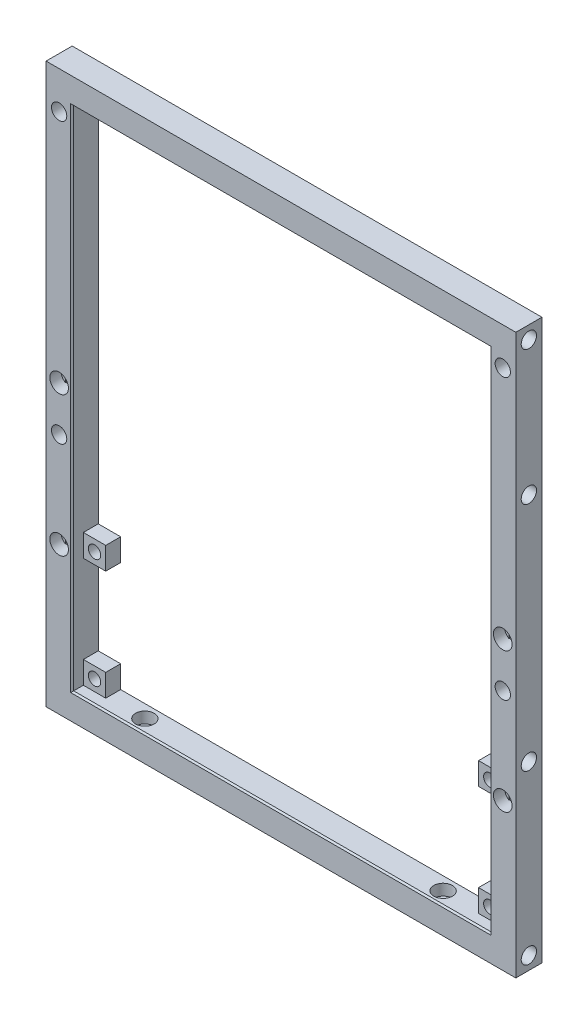
from build123d import *

# Parameters (mm, degrees)
SKETCH1_W           = 126
SKETCH1_H           = 150
SKETCH1_W_2         = 112
SKETCH1_H_2         = 136
BOSS_EXTRUDE1_DEPTH = 7
SKETCH2_R           = 2.05
CUT_EXTRUDE1_DEPTH  = 6
SKETCH3_R           = 1.35
CUT_EXTRUDE2_DEPTH  = 8
SKETCH4_R           = 2.5
CUT_EXTRUDE3_DEPTH  = 3
SKETCH5_R           = 1.35
CUT_EXTRUDE4_DEPTH  = 8
SKETCH6_R           = 2.5
CUT_EXTRUDE5_DEPTH  = 3
CUT_EXTRUDE6_DEPTH  = 0.2
SKETCH8_W           = 2.7
SKETCH8_H           = 2.7
CUT_EXTRUDE7_DEPTH  = 0.2
SKETCH9_R           = 2.05
CUT_EXTRUDE8_DEPTH  = 8
SKETCH10_W          = 6
SKETCH10_H          = 6
BOSS_EXTRUDE2_DEPTH = 4
SKETCH11_R          = 1.65
CUT_EXTRUDE9_DEPTH  = 5
CHAMFER1_SIZE       = 0.4


with BuildPart() as part:
    # Sketch1 → Boss-Extrude1 (new body)
    with BuildSketch(Plane.XY):
        Rectangle(SKETCH1_W, SKETCH1_H)
        Rectangle(SKETCH1_W_2, SKETCH1_H_2, mode=Mode.SUBTRACT)
    extrude(amount=BOSS_EXTRUDE1_DEPTH)

    # Sketch2 → Cut-Extrude1 (cut)
    with BuildSketch(Plane(origin=(63, 0, 0), x_dir=(0, 0, -1), z_dir=(1, 0, 0))):
        with Locations((-3.5, 71.5)):
            Circle(SKETCH2_R)
        with Locations((-3.5, -71.5)):
            Circle(SKETCH2_R)
        with Locations((-3.5, 35.5)):
            Circle(SKETCH2_R)
        with Locations((-3.5, -26.5)):
            Circle(SKETCH2_R)
    cut_extrude1 = extrude(amount=-CUT_EXTRUDE1_DEPTH, mode=Mode.SUBTRACT)

    # Mirror1: Cut-Extrude1 across plane
    add(cut_extrude1.mirror(Plane(origin=(0, 0, 0), x_dir=(0, 0, 1), z_dir=(1, 0, 0))), mode=Mode.SUBTRACT)

    # Sketch3 → Cut-Extrude2 (cut, through all)
    with BuildSketch(Plane(origin=(0, -68, 0), x_dir=(1, 0, 0), z_dir=(0, 1, 0))):
        with Locations((-40, -3.5)):
            Circle(SKETCH3_R)
        with Locations((40, -3.5)):
            Circle(SKETCH3_R)
    extrude(amount=-CUT_EXTRUDE2_DEPTH, mode=Mode.SUBTRACT)

    # Sketch4 → Cut-Extrude3 (cut)
    with BuildSketch(Plane(origin=(0, -68, 0), x_dir=(1, 0, 0), z_dir=(0, 1, 0))):
        with Locations((-40, -3.5)):
            Circle(SKETCH4_R)
        with Locations((40, -3.5)):
            Circle(SKETCH4_R)
    extrude(amount=-CUT_EXTRUDE3_DEPTH, mode=Mode.SUBTRACT)

    # Sketch5 → Cut-Extrude4 (cut, through all)
    with BuildSketch(Plane.XY.offset(7)):
        with Locations((-59.5, 2)):
            Circle(SKETCH5_R)
        with Locations((59.5, 2)):
            Circle(SKETCH5_R)
        with Locations((-59.5, -35.5)):
            Circle(SKETCH5_R)
        with Locations((59.5, -35.5)):
            Circle(SKETCH5_R)
    extrude(amount=-CUT_EXTRUDE4_DEPTH, mode=Mode.SUBTRACT)

    # Sketch6 → Cut-Extrude5 (cut)
    with BuildSketch(Plane.XY.offset(7)):
        with Locations((-59.5, 2)):
            Circle(SKETCH6_R)
        with Locations((59.5, 2)):
            Circle(SKETCH6_R)
        with Locations((-59.5, -35.5)):
            Circle(SKETCH6_R)
        with Locations((59.5, -35.5)):
            Circle(SKETCH6_R)
    extrude(amount=-CUT_EXTRUDE5_DEPTH, mode=Mode.SUBTRACT)

    # Sketch7 → Cut-Extrude6 (cut)
    with BuildSketch(Plane.XY.offset(4)):
        with BuildLine():
            Line((-60.85, -0.104162541), (-60.85, 4.104162541))
            ThreePointArc((-60.85, 4.104162541), (-59.5, 4.5), (-58.15, 4.104162541))
            Line((-58.15, 4.104162541), (-58.15, -0.104162541))
            ThreePointArc((-58.15, -0.104162541), (-59.5, -0.5), (-60.85, -0.104162541))
        make_face()
        with BuildLine():
            Line((-60.85, -37.604162541), (-60.85, -33.395837459))
            ThreePointArc((-60.85, -33.395837459), (-59.5, -33), (-58.15, -33.395837459))
            Line((-58.15, -33.395837459), (-58.15, -37.604162541))
            ThreePointArc((-58.15, -37.604162541), (-59.5, -38), (-60.85, -37.604162541))
        make_face()
    cut_extrude6 = extrude(amount=-CUT_EXTRUDE6_DEPTH, mode=Mode.SUBTRACT)

    # Sketch8 → Cut-Extrude7 (cut)
    with BuildSketch(Plane.XY.offset(3.8)):
        with Locations((-59.5, -35.5)):
            Rectangle(SKETCH8_W, SKETCH8_H)
        with Locations((-59.5, 2)):
            Rectangle(SKETCH8_W, SKETCH8_H)
    cut_extrude7 = extrude(amount=-CUT_EXTRUDE7_DEPTH, mode=Mode.SUBTRACT)

    # Mirror2: Cut-Extrude6, Cut-Extrude7 across plane
    add(cut_extrude6.mirror(Plane(origin=(0, 0, 0), x_dir=(0, 0, 1), z_dir=(1, 0, 0))), mode=Mode.SUBTRACT)
    add(cut_extrude7.mirror(Plane(origin=(0, 0, 0), x_dir=(0, 0, 1), z_dir=(1, 0, 0))), mode=Mode.SUBTRACT)

    # Sketch9 → Cut-Extrude8 (cut, through all)
    with BuildSketch(Plane.XY.offset(7)):
        with Locations((-59.5, 65)):
            Circle(SKETCH9_R)
        with Locations((-59.5, -10)):
            Circle(SKETCH9_R)
    cut_extrude8 = extrude(amount=-CUT_EXTRUDE8_DEPTH, mode=Mode.SUBTRACT)

    # Mirror3: Cut-Extrude8 across plane
    add(cut_extrude8.mirror(Plane(origin=(0, 0, 0), x_dir=(0, 0, 1), z_dir=(1, 0, 0))), mode=Mode.SUBTRACT)

    # Sketch10 → Boss-Extrude2 (add)
    with BuildSketch(Plane(origin=(0, 0, 0), x_dir=(-1, 0, 0), z_dir=(0, 0, -1))):
        with Locations((53, -65)):
            Rectangle(SKETCH10_W, SKETCH10_H)
        with Locations((53, -35.5)):
            Rectangle(SKETCH10_W, SKETCH10_H)
    boss_extrude2 = extrude(amount=-BOSS_EXTRUDE2_DEPTH)

    # Sketch11 → Cut-Extrude9 (cut, through all)
    with BuildSketch(Plane.XY.offset(4)):
        with Locations((-53, -65)):
            Circle(SKETCH11_R)
        with Locations((-53, -35.5)):
            Circle(SKETCH11_R)
    cut_extrude9 = extrude(amount=-CUT_EXTRUDE9_DEPTH, mode=Mode.SUBTRACT)

    # Mirror4: Boss-Extrude2, Cut-Extrude9 across plane
    add(boss_extrude2.mirror(Plane(origin=(0, 0, 0), x_dir=(0, 0, 1), z_dir=(1, 0, 0))))
    add(cut_extrude9.mirror(Plane(origin=(0, 0, 0), x_dir=(0, 0, 1), z_dir=(1, 0, 0))), mode=Mode.SUBTRACT)

    # Chamfer1
    chamfer1_edges = [part.edges().sort_by_distance(p)[0] for p in [
        (56, 0, 7),
        (0, 68, 7),
        (-56, 0, 7),
        (0, -68, 7),
    ]]
    chamfer(chamfer1_edges, length=CHAMFER1_SIZE)


solid = part.part
